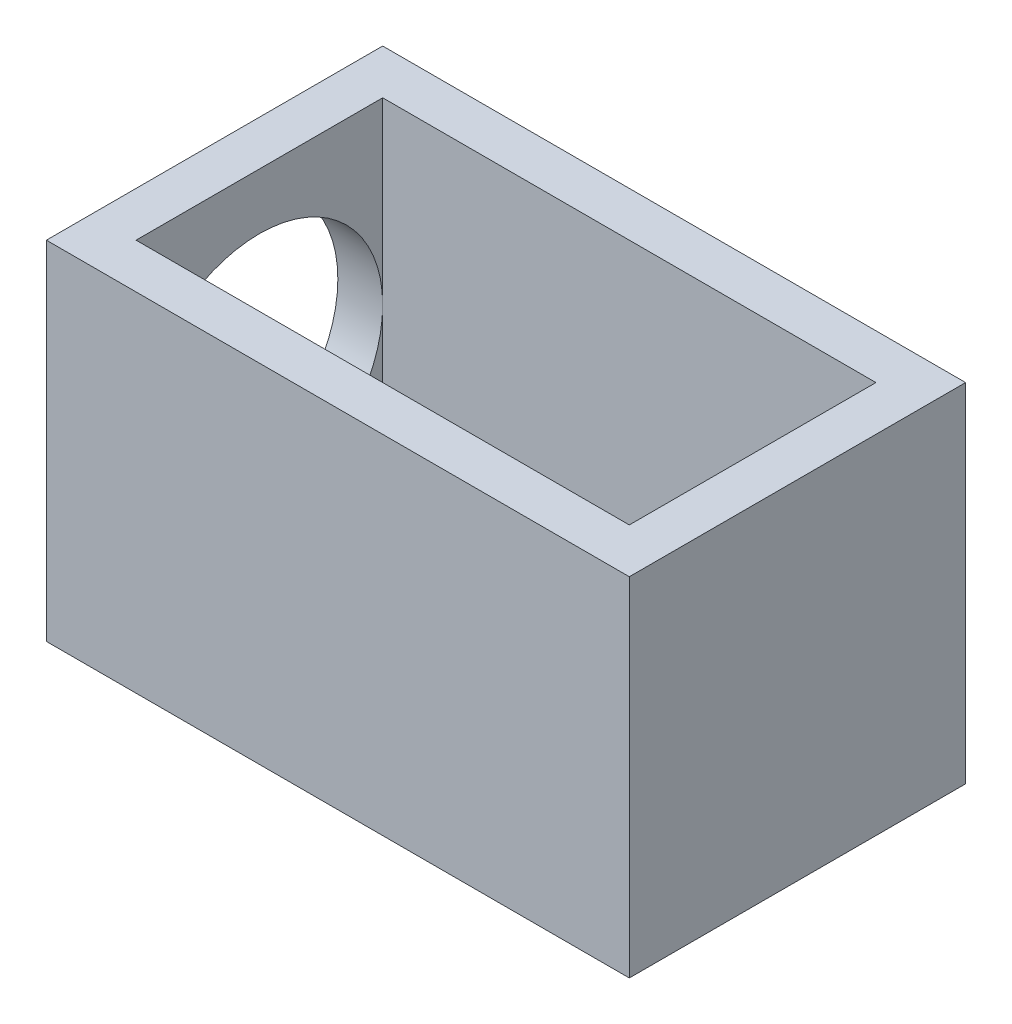
from build123d import *

# Parameters (mm, degrees)
SKETCH1_W           = 13
SKETCH1_H           = 7.5
SKETCH1_W_2         = 11
SKETCH1_H_2         = 5.5
BOSS_EXTRUDE1_DEPTH = 7.75
SKETCH2_R           = 2.75
CUT_EXTRUDE1_DEPTH  = 1
SKETCH3_W           = 13
SKETCH3_H           = 7.5
BOSS_EXTRUDE2_DEPTH = 1
BOSS_EXTRUDE3_DEPTH = 3


with BuildPart() as part:
    # Sketch1 → Boss-Extrude1 (new body)
    with BuildSketch(Plane(origin=(0, 0, 0), x_dir=(1, 0, 0), z_dir=(0, 1, 0))):
        Rectangle(SKETCH1_W, SKETCH1_H)
        Rectangle(SKETCH1_W_2, SKETCH1_H_2, mode=Mode.SUBTRACT)
    extrude(amount=BOSS_EXTRUDE1_DEPTH)

    # Sketch2 → Cut-Extrude1 (cut)
    with BuildSketch(Plane.ZY.offset(6.5)):
        with Locations((0, 3.75)):
            Circle(SKETCH2_R)
    extrude(amount=-CUT_EXTRUDE1_DEPTH, mode=Mode.SUBTRACT)

    # Sketch3 → Boss-Extrude2 (add)
    with BuildSketch(Plane.XZ):
        Rectangle(SKETCH3_W, SKETCH3_H)
    extrude(amount=-BOSS_EXTRUDE2_DEPTH)

    # Sketch4 → Boss-Extrude3 (add, symmetric)
    with BuildSketch(Plane.XY):
        Polygon((2.25, 1), (5.5, 6.5), (5.5, 1), align=None)
    extrude(amount=BOSS_EXTRUDE3_DEPTH, both=True)


solid = part.part
